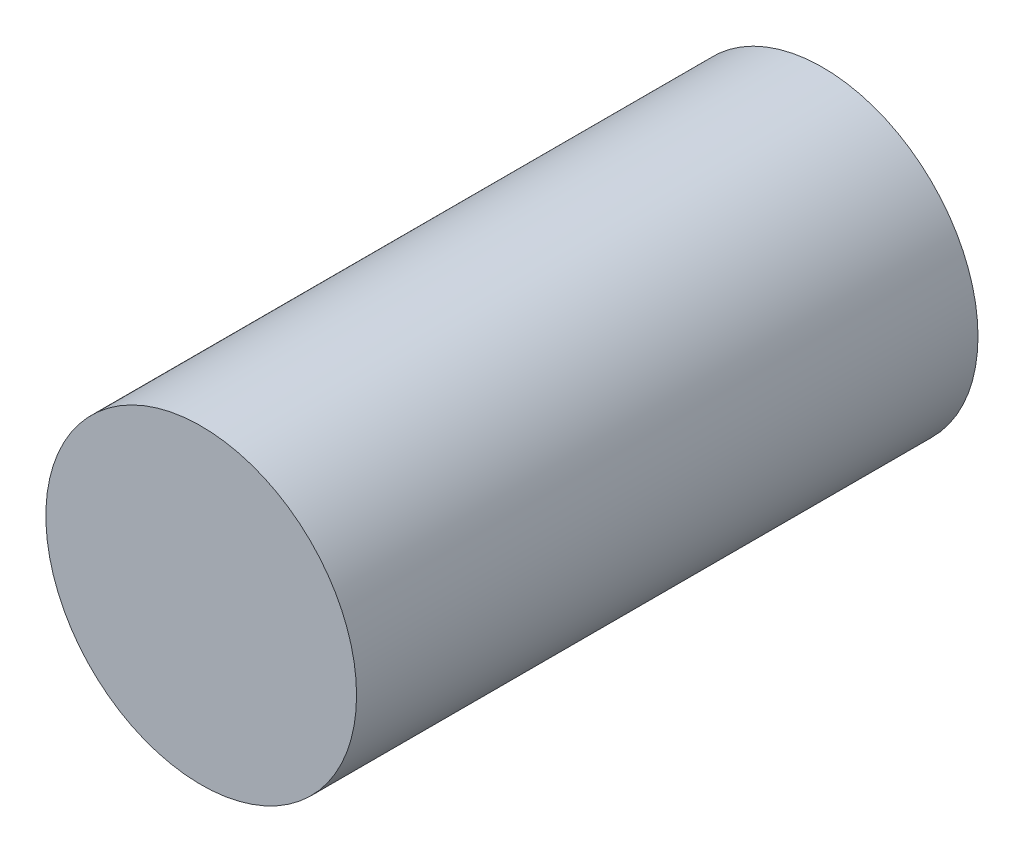
from build123d import *

# Parameters (mm, degrees)
ESBO_O1_R                = 2.5
RESSALTO_EXTRUS_O1_DEPTH = 10


with BuildPart() as part:
    # Esboço1 → Ressalto-extrusão1 (new body)
    with BuildSketch(Plane.XY):
        Circle(ESBO_O1_R)
    extrude(amount=RESSALTO_EXTRUS_O1_DEPTH)


solid = part.part
